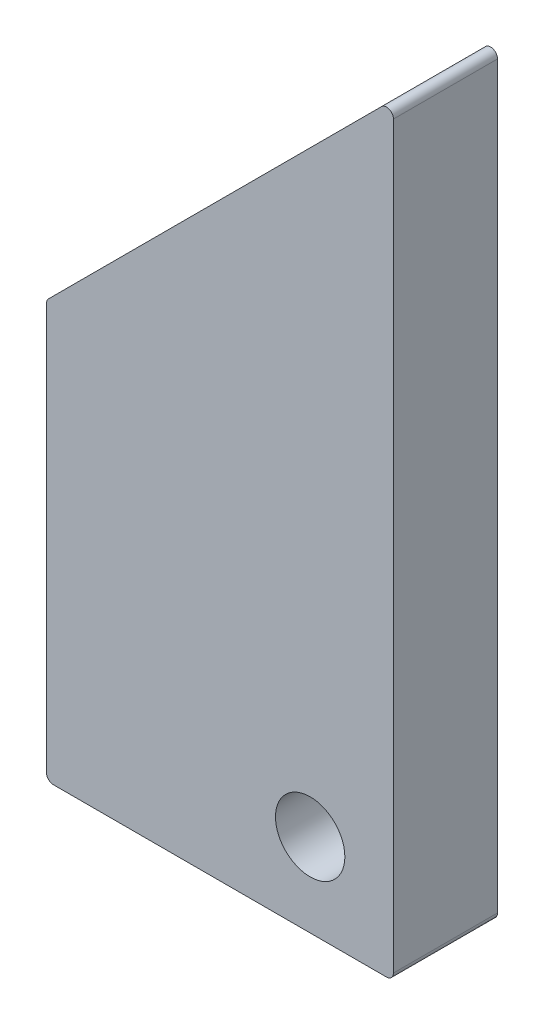
from build123d import *

# Parameters (mm, degrees)
SCHIZZO1_R                   = 5
ESTRUSIONE_ESTRUSIONE1_DEPTH = 15
RACCORDO1_R                  = 1


with BuildPart() as part:
    # Schizzo1 → Estrusione-Estrusione1 (new body)
    with BuildSketch(Plane.XY):
        Polygon((0, 0), (0, 110), (-50, 60), (-50, 0), align=None)
        with Locations((-12, 12)):
            Circle(SCHIZZO1_R, mode=Mode.SUBTRACT)
    extrude(amount=ESTRUSIONE_ESTRUSIONE1_DEPTH)

    # Raccordo1
    raccordo1_edges = [part.edges().sort_by_distance(p)[0] for p in [
        (-50, 0, 7.5),
        (-50, 60, 7.5),
        (0, 110, 7.5),
        (0, 0, 7.5),
    ]]
    fillet(raccordo1_edges, radius=RACCORDO1_R)


solid = part.part
